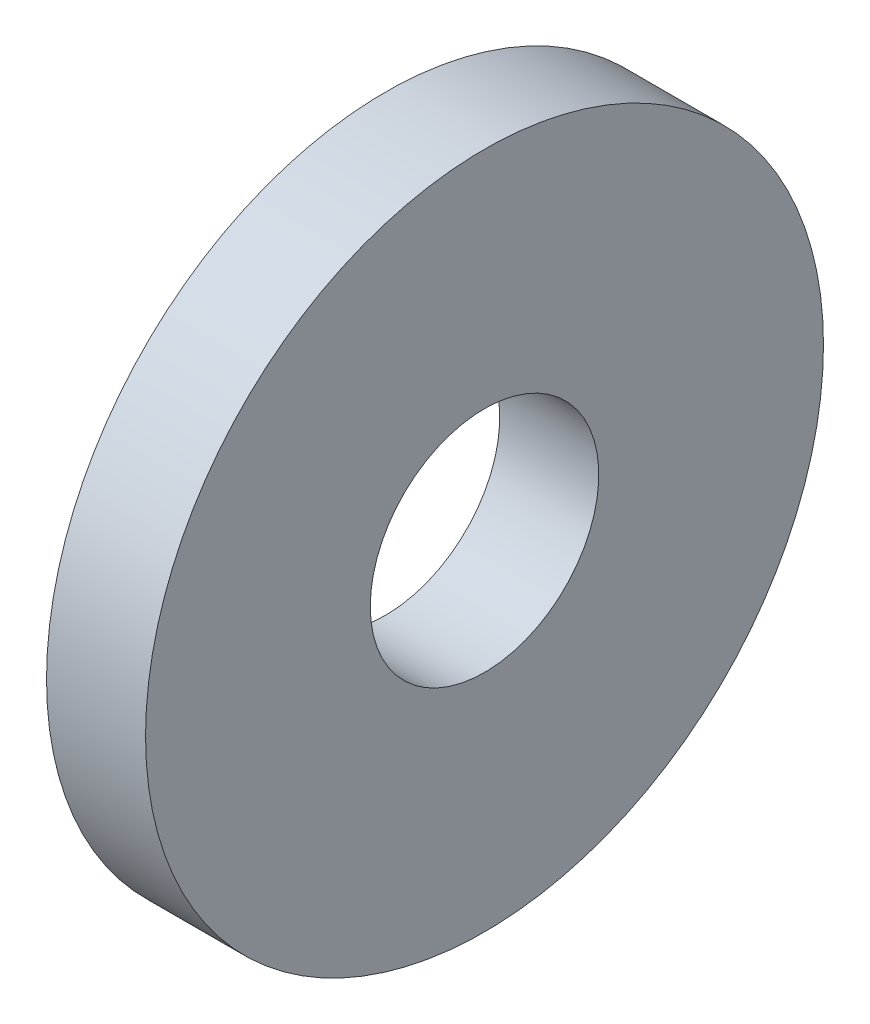
from build123d import *

# Parameters (mm, degrees)
SKETCH1_W = 1.3
SKETCH1_H = 2.95


with BuildPart() as part:
    # Sketch1 → Revolve1 (revolve)
    with BuildSketch(Plane.XY):
        with Locations((0.65, 2.975)):
            Rectangle(SKETCH1_W, SKETCH1_H)
    revolve(axis=Axis((-18.026847945, 0, 0), (1, 0, 0)))


solid = part.part
